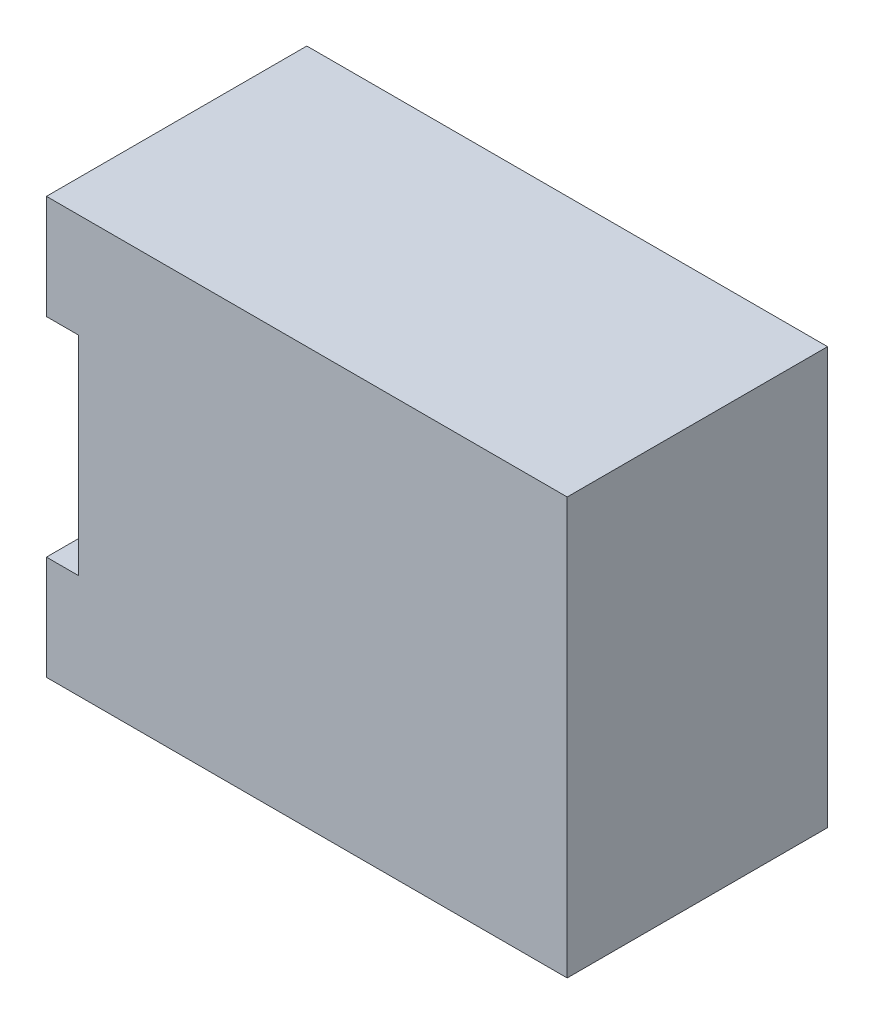
from build123d import *

# Parameters (mm, degrees)
RESSALTO_EXTRUS_O1_DEPTH = 32.5


with BuildPart() as part:
    # Esboço1 → Ressalto-extrusão1 (new body)
    with BuildSketch(Plane.XY):
        Polygon((-40.975787988, 17.333333333), (-36.975787988, 17.333333333), (-36.975787988, -8.666666667), (-40.975787988, -8.666666667), (-40.975787988, -21.666666667), (24.024212012, -21.666666667), (24.024212012, 30.333333333), (-40.975787988, 30.333333333), align=None)
    extrude(amount=RESSALTO_EXTRUS_O1_DEPTH)


solid = part.part
